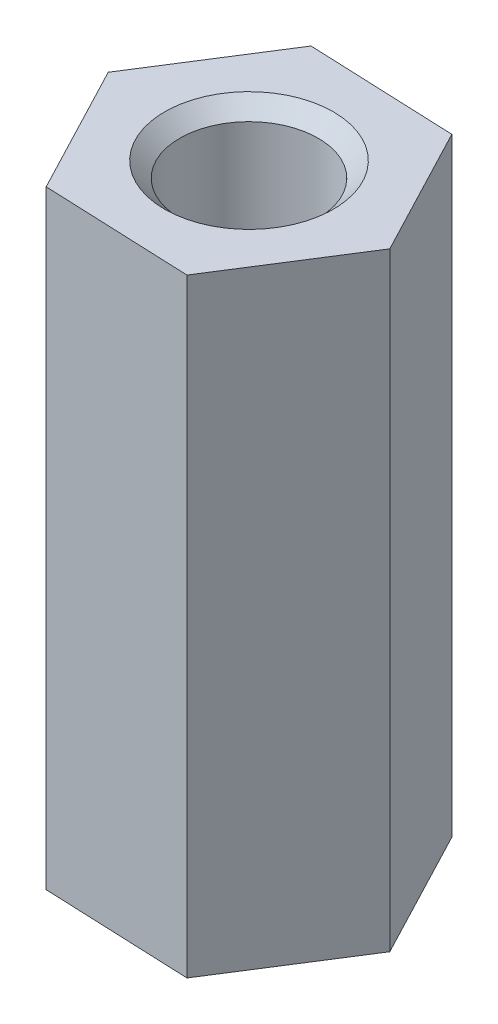
from build123d import *

# Parameters (mm, degrees)
SKETCH_1_R                   = 1.1
EXTRUDE_1_DEPTH              = 11
HOLE_WIZARD_M3_2_D           = 2.5
HOLE_WIZARD_M3_2_CSINK_D     = 3.05
HOLE_WIZARD_M3_2_CSINK_ANGLE = 90


with BuildPart() as part:
    # 草图1 → 凸台-拉伸1 (new body)
    with BuildSketch(Plane(origin=(0, 0, 0), x_dir=(1, 0, 0), z_dir=(0, 1, 0))):
        Polygon((1.231724884, -2.352910356), (2.653542583, -0.109750138), (1.421817699, 2.243160218), (-1.231724884, 2.352910356), (-2.653542583, 0.109750138), (-1.421817699, -2.243160218), align=None)
        Circle(SKETCH_1_R, mode=Mode.SUBTRACT)
    extrude(amount=EXTRUDE_1_DEPTH)

    # M3 螺纹孔2 (through all)
    with Locations(Plane(origin=(0, 11, 0), x_dir=(1, 0, 0), z_dir=(0, 1, 0))):
        with Locations((0, 0)):
            CounterSinkHole(HOLE_WIZARD_M3_2_D / 2, HOLE_WIZARD_M3_2_CSINK_D / 2, counter_sink_angle=HOLE_WIZARD_M3_2_CSINK_ANGLE)


solid = part.part
